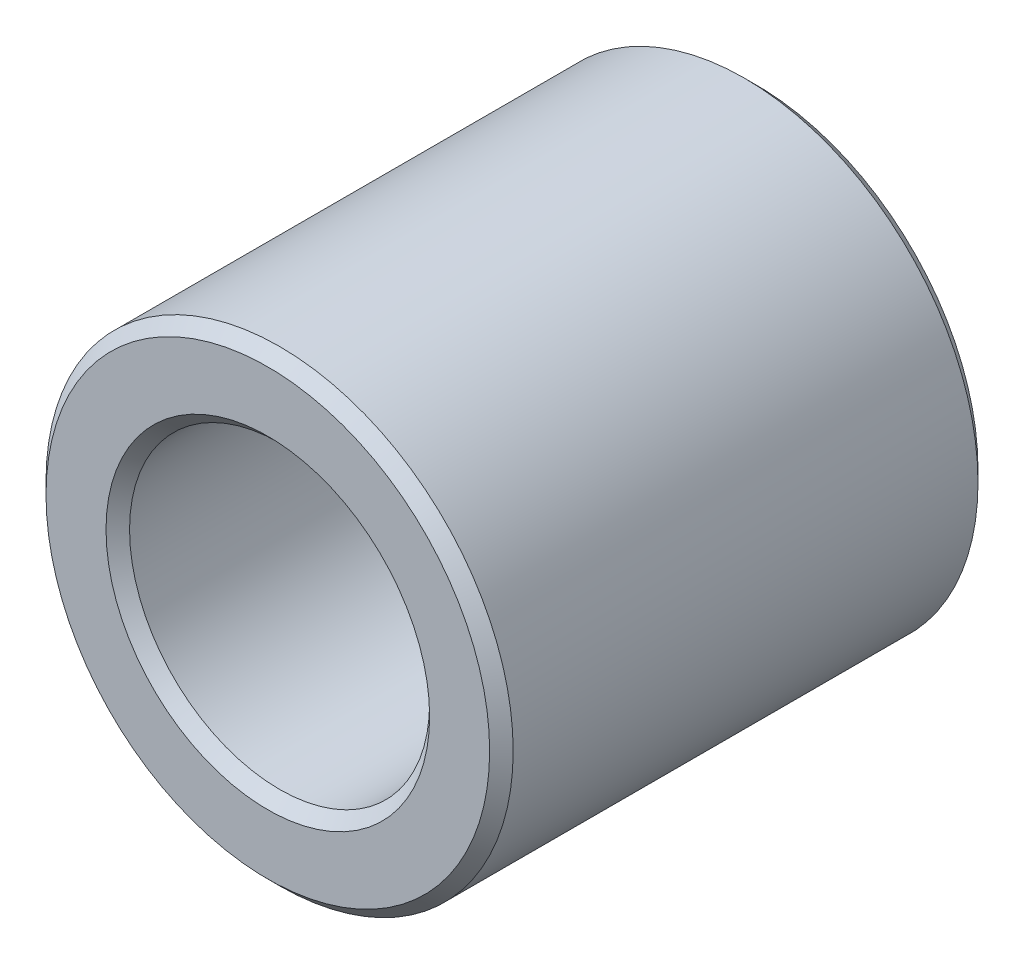
from build123d import *

# Parameters (mm, degrees)
SKETCH1_R           = 3.97
SKETCH1_R_2         = 2.55
BOSS_EXTRUDE1_DEPTH = 8.3
CHAMFER1_SIZE       = 0.2


with BuildPart() as part:
    # Sketch1 → Boss-Extrude1 (new body)
    with BuildSketch(Plane.XY):
        Circle(SKETCH1_R)
        Circle(SKETCH1_R_2, mode=Mode.SUBTRACT)
    extrude(amount=BOSS_EXTRUDE1_DEPTH)

    # Chamfer1
    chamfer1_edges = [part.edges().sort_by_distance(p)[0] for p in [
        (-3.97, 0, 0),
        (-3.97, 0, 8.3),
        (-2.55, 0, 0),
        (-2.55, 0, 8.3),
    ]]
    chamfer(chamfer1_edges, length=CHAMFER1_SIZE)


solid = part.part
